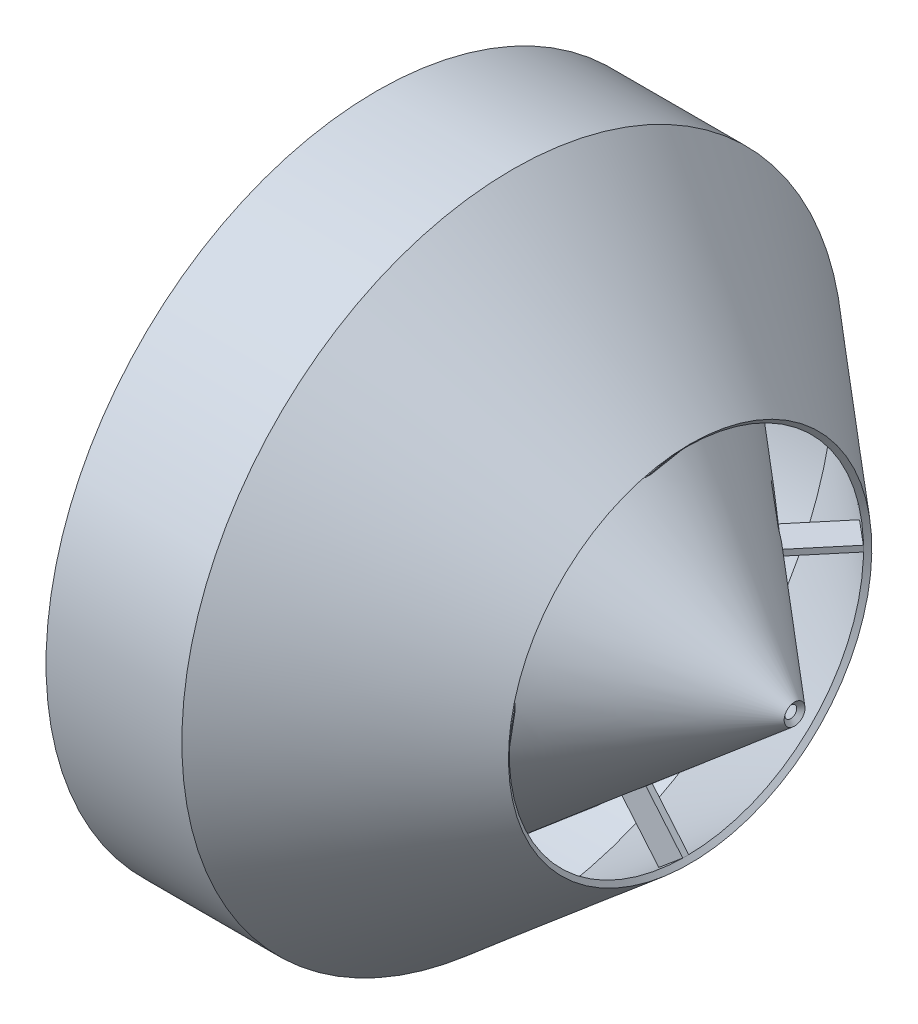
from build123d import *

# Parameters (mm, degrees)
BOSS_EXTRUDE1_DEPTH = 0.635
CIRPATTERN1_COUNT   = 4


with BuildPart() as part:
    # Sketch1 → Revolve1 (revolve)
    with BuildSketch(Plane.XY):
        Polygon((-30.401242848, 69.85), (-1.650713674, 69.85), (36.187462891, 38.1), (37.003803155, 39.072876443), (-1.188471476, 71.12), (-30.401242848, 71.12), align=None)
    revolve(axis=Axis((0, 0, 0), (-1, 0, 0)))



with BuildPart() as body_2:
    # Sketch2 → Revolve2 (revolve)
    with BuildSketch(Plane.XY):
        Polygon((0.784405442, 49.827123557), (1.600745706, 50.8), (59.468872152, 2.242876443), (58.652531887, 1.27), align=None)
    revolve(axis=Axis((0, 0, 0), (-1, 0, 0)))


with BuildPart() as part_1:
    add(part.part)

    add(body_2.part)  # Boss-Extrude1 merges body 2
    # Sketch3 → Boss-Extrude1 (add, symmetric)
    with BuildSketch(Plane.XY):
        Polygon((30.952144014, 42.599035585), (36.107835241, 38.272896978), (27.427825795, 27.928464538), (22.272134568, 32.254603145), align=None)
    boss_extrude1 = extrude(amount=BOSS_EXTRUDE1_DEPTH, both=True)

    # CirPattern1: Boss-Extrude1 ×4 about axis
    cirpattern1_axis = Axis((0, 0, 0), (1, 0, 0))
    for i in range(1, CIRPATTERN1_COUNT):
        add(boss_extrude1.rotate(cirpattern1_axis, i * 360 / CIRPATTERN1_COUNT))


solid = part_1.part
